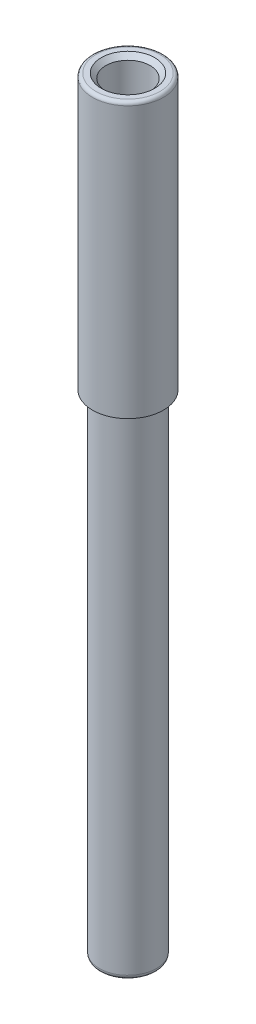
from build123d import *

# Parameters (mm, degrees)
SKETCH1_R                        = 3.175
BOSS_EXTRUDE1_DEPTH              = 57.15
F_10_0_1935_DIAMETER_HOLE1_D     = 4.9149
F_10_0_1935_DIAMETER_HOLE1_DEPTH = 54.61
F_10_0_1935_DIAMETER_HOLE1_TIP   = 1.476584928
SKETCH5_R                        = 3.937
SKETCH5_R_2                      = 3.175
BOSS_EXTRUDE2_DEPTH              = 2.54
FILLET1_R                        = 0.508
SKETCH6_R                        = 3.937
SKETCH6_R_2                      = 2.45745
BOSS_EXTRUDE3_DEPTH              = 27.94
CHAMFER1_SIZE                    = 0.508
FILLET2_R                        = 0.381


with BuildPart() as part:
    # Sketch1 → Boss-Extrude1 (new body)
    with BuildSketch(Plane(origin=(0, 0, 0), x_dir=(1, 0, 0), z_dir=(0, 1, 0))):
        Circle(SKETCH1_R)
    extrude(amount=BOSS_EXTRUDE1_DEPTH)

    # #10 (0.1935) Diameter Hole1
    with Locations(Plane.ZX.offset(57.15)):
        with Locations((0, 0)):
            Hole(F_10_0_1935_DIAMETER_HOLE1_D / 2, depth=F_10_0_1935_DIAMETER_HOLE1_DEPTH)
            with Locations((0, 0, -(F_10_0_1935_DIAMETER_HOLE1_DEPTH + F_10_0_1935_DIAMETER_HOLE1_TIP / 2))):  # 118° drill point
                Cone(0, F_10_0_1935_DIAMETER_HOLE1_D / 2, F_10_0_1935_DIAMETER_HOLE1_TIP, mode=Mode.SUBTRACT)

    # Sketch5 → Boss-Extrude2 (add)
    with BuildSketch(Plane(origin=(0, 57.15, 0), x_dir=(1, 0, 0), z_dir=(0, 1, 0))):
        Circle(SKETCH5_R)
        Circle(SKETCH5_R_2, mode=Mode.SUBTRACT)
    extrude(amount=-BOSS_EXTRUDE2_DEPTH)

    # Fillet1
    fillet1_edges = [part.edges().sort_by_distance(p)[0] for p in [
        (-3.175, 0, 0),
    ]]
    fillet(fillet1_edges, radius=FILLET1_R)

    # Sketch6 → Boss-Extrude3 (add)
    with BuildSketch(Plane(origin=(0, 57.15, 0), x_dir=(1, 0, 0), z_dir=(0, 1, 0))):
        Circle(SKETCH6_R)
        Circle(SKETCH6_R_2, mode=Mode.SUBTRACT)
    extrude(amount=BOSS_EXTRUDE3_DEPTH)

    # Chamfer1
    chamfer1_edges = [part.edges().sort_by_distance(p)[0] for p in [
        (-2.45745, 85.09, 0),
    ]]
    chamfer(chamfer1_edges, length=CHAMFER1_SIZE)

    # Fillet2
    fillet2_edges = [part.edges().sort_by_distance(p)[0] for p in [
        (-3.937, 85.09, 0),
    ]]
    fillet(fillet2_edges, radius=FILLET2_R)


solid = part.part
